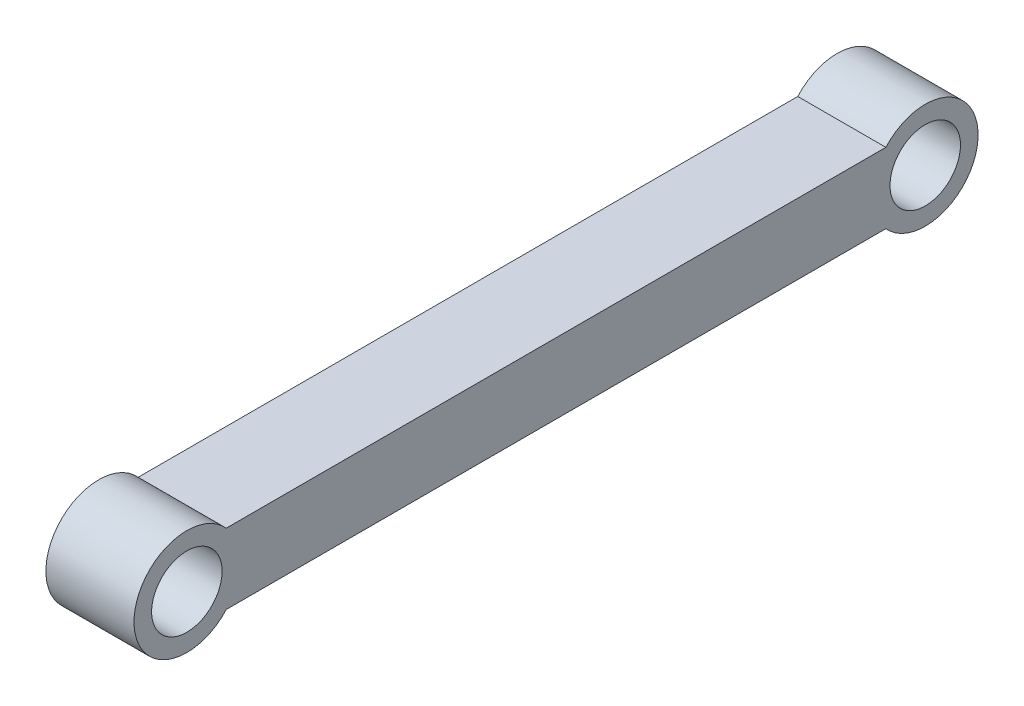
from build123d import *

# Parameters (mm, degrees)
LINKFRAME_R         = 40
BOSS_EXTRUDE1_DEPTH = 100


with BuildPart() as part:
    # LinkFrame → Boss-Extrude1 (new body)
    with BuildSketch(Plane(origin=(0, 0, 0), x_dir=(0, 0, -1), z_dir=(1, 0, 0))):
        with BuildLine():
            Line((-533.81417903, -186.263273145), (214.93310187, -186.263273145))
            ThreePointArc((214.93310187, -186.263273145), (319.65446142, -226.263273145), (214.93310187, -266.263273145))
            Line((214.93310187, -266.263273145), (-533.81417903, -266.263273145))
            ThreePointArc((-533.81417903, -266.263273145), (-638.53553858, -226.263273145), (-533.81417903, -186.263273145))
        make_face()
        with Locations((-578.53553858, -226.263273145)):
            Circle(LINKFRAME_R, mode=Mode.SUBTRACT)
        with Locations((259.65446142, -226.263273145)):
            Circle(LINKFRAME_R, mode=Mode.SUBTRACT)
    extrude(amount=BOSS_EXTRUDE1_DEPTH)


solid = part.part
